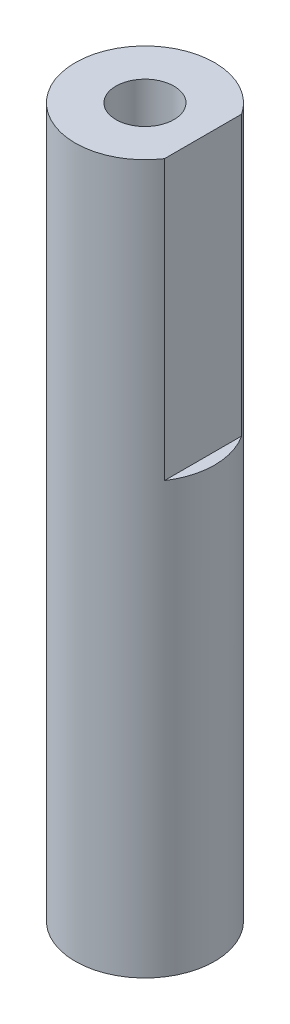
from build123d import *

# Parameters (mm, degrees)
SKETCH1_R                 = 3
SHAFT_DEPTH               = 20.5
SHAFT_DEPTH_BACK          = 10
SKETCH2_W                 = 0.5
SKETCH2_H                 = 6
KEY_DEPTH                 = 12
M3X0_5_TAPPED_HOLE1_D     = 2.5
M3X0_5_TAPPED_HOLE1_DEPTH = 14.5
M3X0_5_TAPPED_HOLE1_TIP   = 0.751075774


with BuildPart() as part:
    # Sketch1 → SHAFT (new body, two sides)
    with BuildSketch(Plane(origin=(0, 0, 0), x_dir=(1, 0, 0), z_dir=(0, 1, 0))) as shaft_sk:
        Circle(SKETCH1_R)
    extrude(amount=SHAFT_DEPTH)
    extrude(shaft_sk.sketch, amount=-SHAFT_DEPTH_BACK)

    # Sketch2 → KEY (cut)
    with BuildSketch(Plane(origin=(0, 20.5, 0), x_dir=(1, 0, 0), z_dir=(0, 1, 0))):
        with Locations((2.75, 0)):
            Rectangle(SKETCH2_W, SKETCH2_H)
    extrude(amount=-KEY_DEPTH, mode=Mode.SUBTRACT)

    # M3x0.5 Tapped Hole1
    with Locations(Plane(origin=(0, 20.5, 0), x_dir=(1, 0, 0), z_dir=(0, 1, 0))):
        with Locations((0, 0)):
            Hole(M3X0_5_TAPPED_HOLE1_D / 2, depth=M3X0_5_TAPPED_HOLE1_DEPTH)
            with Locations((0, 0, -(M3X0_5_TAPPED_HOLE1_DEPTH + M3X0_5_TAPPED_HOLE1_TIP / 2))):  # 118° drill point
                Cone(0, M3X0_5_TAPPED_HOLE1_D / 2, M3X0_5_TAPPED_HOLE1_TIP, mode=Mode.SUBTRACT)


solid = part.part
